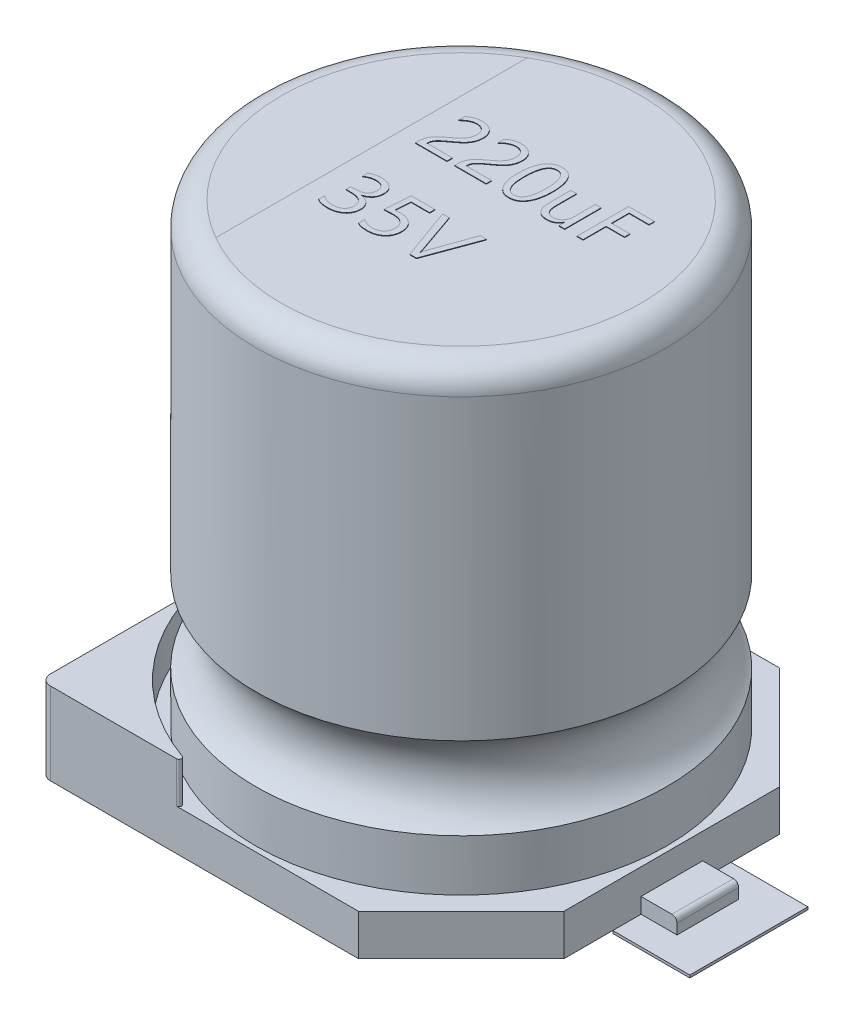
from build123d import *

# Parameters (mm, degrees)
SKETCH1_R             = 4
BOSS_EXTRUDE1_DEPTH   = 8.9
FILLET1_R             = 0.5
SKETCH3_W             = 8.2
SKETCH3_H             = 8.2
BOSS_EXTRUDE2_DEPTH   = 0.8
CHAMFER1_SIZE         = 2
BOSS_EXTRUDE3_DEPTH   = 0.8
FILLET2_R             = 0.05
SKETCH5_W             = 1.2
SKETCH5_H             = 0.3
BOSS_EXTRUDE4_DEPTH   = 0.7
FILLET3_R             = 0.1
FILLET4_R             = 0.2
BOSS_EXTRUDE5_DEPTH   = 0.01
SKETCH8_W             = 1.5
SKETCH8_H             = 2.3
BOSS_EXTRUDE6_DEPTH   = 0.05
BOSS_EXTRUDE6_2_DEPTH = 0.05


with BuildPart() as part:
    # Sketch1 → Boss-Extrude1 (new body)
    with BuildSketch(Plane(origin=(0, 0, 0), x_dir=(1, 0, 0), z_dir=(0, 1, 0))):
        with Locations(Location((0, 0, 0), (0, 0, 270))):
            Circle(SKETCH1_R)
    extrude(amount=BOSS_EXTRUDE1_DEPTH)

    # Sketch2 → Cut-Revolve1 (revolve, cut)
    with BuildSketch(Plane.XY, mode=Mode.PRIVATE) as cut_revolve1_sk:
        with BuildLine():
            Line((-4, 2.6), (-4, 1))
            ThreePointArc((-4, 1), (-3.6, 1.8), (-4, 2.6))
        make_face()
    revolve(cut_revolve1_sk.sketch.rotate(Axis((0, 0, 0), (0, 1, 0)), 270), axis=Axis((0, 0, 0), (0, 1, 0)), mode=Mode.SUBTRACT)

    # Fillet1
    fillet1_edges = [part.edges().sort_by_distance(p)[0] for p in [
        (0, 8.9, -4),
    ]]
    fillet(fillet1_edges, radius=FILLET1_R)

    # Sketch7 → Boss-Extrude5 (add)
    with BuildSketch(Plane(origin=(0, 8.9, 0), x_dir=(1, 0, 0), z_dir=(0, 1, 0))):
        with BuildLine():
            add(Edge.make_bspline(
                [(-0.930125802, 1.236413932), (-0.930259114, 1.243960657), (-0.93051816, 1.258625219), (-0.933217585, 1.279837795), (-0.937690446, 1.299566075), (-0.94413612, 1.317704314), (-0.951973463, 1.334404835), (-0.960965693, 1.349697986), (-0.971418987, 1.363460373), (-0.983054115, 1.375758821), (-0.996025952, 1.386549119), (-1.009932817, 1.396056003), (-1.025099003, 1.403860125), (-1.041211775, 1.410259329), (-1.058234602, 1.415152609), (-1.075995938, 1.418551202), (-1.094393633, 1.421022673), (-1.106926382, 1.42116749), (-1.113308368, 1.421241235)],
                knots=[0, 0, 0, 0, 1.229976224, 2.390051507, 3.479695195, 4.522256188, 5.522020781, 6.484042306, 7.409278233, 8.334041706, 9.238256106, 10.155631384, 11.07524972, 12.01315198, 12.978606878, 13.958184871, 14.960257312, 16, 16, 16, 16], degree=3))
            add(Edge.make_bspline(
                [(-1.113308368, 1.421241235), (-1.124306368, 1.420793323), (-1.146359305, 1.419895181), (-1.178872583, 1.413005858), (-1.210521013, 1.40241095), (-1.241171261, 1.388330314), (-1.270914684, 1.371112065), (-1.299540216, 1.351126167), (-1.326558952, 1.328232214), (-1.343084419, 1.311316023), (-1.351384026, 1.302820182)],
                knots=[0, 0, 0, 0, 0.965628522, 1.936256016, 2.907294264, 3.893428475, 4.89415936, 5.923092914, 6.956912204, 8, 8, 8, 8], degree=3))
            Line((-1.351384026, 1.302820182), (-1.351384026, 1.42083005))
            add(Edge.make_bspline(
                [(-1.351384026, 1.42083005), (-1.343296156, 1.428056334), (-1.327247541, 1.442395319), (-1.300949265, 1.460807107), (-1.273441566, 1.476863251), (-1.244116711, 1.490122212), (-1.212383716, 1.500911096), (-1.177569131, 1.507976142), (-1.139616176, 1.512689044), (-1.11325576, 1.513121421), (-1.099533697, 1.513346498)],
                knots=[0, 0, 0, 0, 0.944214214, 1.873587351, 2.791167331, 3.715694743, 4.672957526, 5.704638579, 6.805136737, 8, 8, 8, 8], degree=3))
            add(Edge.make_bspline(
                [(-1.099533697, 1.513346498), (-1.089518573, 1.513173106), (-1.069843055, 1.512832463), (-1.040894307, 1.509428442), (-1.013088783, 1.50395329), (-0.986554824, 1.496101614), (-0.961388457, 1.486300469), (-0.937913947, 1.474271219), (-0.915882319, 1.460578007), (-0.895977467, 1.444386562), (-0.877700025, 1.426484826), (-0.861591307, 1.406379899), (-0.847568662, 1.384232224), (-0.835639917, 1.360212472), (-0.826140454, 1.334227892), (-0.819073757, 1.306500097), (-0.815276422, 1.276814851), (-0.814682385, 1.256503336), (-0.814377447, 1.246076761)],
                knots=[0, 0, 0, 0, 1.090983638, 2.143325233, 3.171486627, 4.175802002, 5.154894058, 6.110112073, 7.046608623, 7.976171165, 8.900318033, 9.829880575, 10.776682924, 11.751922351, 12.746640181, 13.786318399, 14.863643788, 16, 16, 16, 16], degree=3))
            add(Edge.make_bspline(
                [(-0.814377447, 1.246076761), (-0.814531458, 1.236477477), (-0.814832315, 1.217725566), (-0.817296719, 1.190235014), (-0.821581293, 1.1641952), (-0.827589826, 1.139459526), (-0.835290949, 1.115847829), (-0.84452299, 1.092916153), (-0.85568986, 1.07066016), (-0.86861869, 1.04908191), (-0.883474866, 1.028235552), (-0.899578239, 1.007520928), (-0.918102774, 0.987695275), (-0.938046494, 0.967928986), (-0.95974411, 0.948246214), (-0.983540843, 0.928904371), (-1.008684502, 0.908805781), (-1.026491879, 0.895947355), (-1.035594552, 0.889374458)],
                knots=[0, 0, 0, 0, 1.04820289, 2.047632774, 3.011021103, 3.927694667, 4.824695696, 5.721103316, 6.624792092, 7.54122121, 8.465198091, 9.418974354, 10.404208392, 11.42559055, 12.48532564, 13.601687869, 14.7740444, 16, 16, 16, 16], degree=3))
            add(Edge.make_bspline(
                [(-1.035594552, 0.889374458), (-1.0467608, 0.881350886), (-1.068090672, 0.866024183), (-1.098747881, 0.844129319), (-1.125870649, 0.823476711), (-1.150532456, 0.804966697), (-1.172179314, 0.787392622), (-1.191598763, 0.770750028), (-1.208272601, 0.754276876), (-1.22317442, 0.738674783), (-1.235595167, 0.723065216), (-1.246188175, 0.70768586), (-1.254710812, 0.692205633), (-1.261205012, 0.676468123), (-1.265985539, 0.660195794), (-1.26919072, 0.642970859), (-1.271348594, 0.624626665), (-1.271523986, 0.611968811), (-1.271614289, 0.605451761)],
                knots=[0, 0, 0, 0, 1.708614713, 3.263812021, 4.68081799, 5.944582465, 7.094984069, 8.145209792, 9.120763434, 10.006432465, 10.824334392, 11.596681272, 12.324558074, 13.015639001, 13.708135059, 14.427947188, 15.190609529, 16, 16, 16, 16], degree=3))
            Line((-1.271614289, 0.605451761), (-0.776137315, 0.605451761))
            Line((-0.776137315, 0.605451761), (-0.776137315, 0.500188603))
            Line((-0.776137315, 0.500188603), (-1.390240934, 0.500188603))
            Line((-1.390240934, 0.500188603), (-1.390240934, 0.549530708))
            add(Edge.make_bspline(
                [(-1.390240934, 0.549530708), (-1.390112493, 0.559885514), (-1.389862806, 0.580015245), (-1.387089622, 0.609264891), (-1.382867614, 0.636617894), (-1.376895913, 0.662301406), (-1.368836385, 0.68672351), (-1.358190542, 0.710143676), (-1.345652347, 0.73310337), (-1.330653103, 0.755473675), (-1.31330216, 0.777442221), (-1.293576524, 0.799395571), (-1.271447887, 0.821266274), (-1.246596291, 0.843251792), (-1.219042309, 0.865837507), (-1.188798854, 0.889960508), (-1.15557999, 0.915331717), (-1.132316114, 0.932513516), (-1.1202985, 0.941389261)],
                knots=[0, 0, 0, 0, 0.993935718, 1.932209879, 2.81819806, 3.64973488, 4.461244427, 5.283013065, 6.11642225, 6.970511397, 7.865615548, 8.802227002, 9.802589001, 10.85121407, 11.986896714, 13.223140369, 14.565534561, 16, 16, 16, 16], degree=3))
            add(Edge.make_bspline(
                [(-1.1202985, 0.941389261), (-1.111641587, 0.947800515), (-1.094865557, 0.960224736), (-1.070876025, 0.978759101), (-1.049583208, 0.997425348), (-1.030060537, 1.015265375), (-1.012617763, 1.033103702), (-0.99707653, 1.050910344), (-0.983161212, 1.068610325), (-0.967478787, 1.091941675), (-0.951391267, 1.121372266), (-0.938714616, 1.1585384), (-0.931274338, 1.196908293), (-0.930513309, 1.223085047), (-0.930125802, 1.236413932)],
                knots=[0, 0, 0, 0, 1.05745301, 2.049213797, 2.974384311, 3.835963594, 4.644633175, 5.421714405, 6.155056683, 6.852828246, 8.179982614, 9.432988448, 10.692908862, 12, 12, 12, 12], degree=3))
        make_face()
        with BuildLine():
            add(Edge.make_bspline(
                [(-0.166967907, 1.236413932), (-0.167101219, 1.243960657), (-0.167360266, 1.258625219), (-0.17005969, 1.279837795), (-0.174532551, 1.299566075), (-0.180978225, 1.317704314), (-0.188815569, 1.334404835), (-0.197807799, 1.349697986), (-0.208261093, 1.363460373), (-0.21989622, 1.375758821), (-0.232868057, 1.386549119), (-0.246774922, 1.396056003), (-0.261941108, 1.403860125), (-0.27805388, 1.410259329), (-0.295076707, 1.415152609), (-0.312838044, 1.418551202), (-0.331235738, 1.421022673), (-0.343768488, 1.42116749), (-0.350150473, 1.421241235)],
                knots=[0, 0, 0, 0, 1.229976224, 2.390051507, 3.479695195, 4.522256188, 5.522020781, 6.484042306, 7.409278233, 8.334041706, 9.238256106, 10.155631384, 11.07524972, 12.01315198, 12.978606878, 13.958184871, 14.960257312, 16, 16, 16, 16], degree=3))
            add(Edge.make_bspline(
                [(-0.350150473, 1.421241235), (-0.361148474, 1.420793323), (-0.38320141, 1.419895181), (-0.415714688, 1.413005858), (-0.447363119, 1.40241095), (-0.478013367, 1.388330314), (-0.507756789, 1.371112065), (-0.536382322, 1.351126167), (-0.563401057, 1.328232214), (-0.579926524, 1.311316023), (-0.588226131, 1.302820182)],
                knots=[0, 0, 0, 0, 0.965628522, 1.936256016, 2.907294264, 3.893428475, 4.89415936, 5.923092914, 6.956912204, 8, 8, 8, 8], degree=3))
            Line((-0.588226131, 1.302820182), (-0.588226131, 1.42083005))
            add(Edge.make_bspline(
                [(-0.588226131, 1.42083005), (-0.580138261, 1.428056334), (-0.564089646, 1.442395319), (-0.53779137, 1.460807107), (-0.510283672, 1.476863251), (-0.480958816, 1.490122212), (-0.449225821, 1.500911096), (-0.414411236, 1.507976142), (-0.376458281, 1.512689044), (-0.350097865, 1.513121421), (-0.336375802, 1.513346498)],
                knots=[0, 0, 0, 0, 0.944214214, 1.873587351, 2.791167331, 3.715694743, 4.672957526, 5.704638579, 6.805136737, 8, 8, 8, 8], degree=3))
            add(Edge.make_bspline(
                [(-0.336375802, 1.513346498), (-0.326360678, 1.513173106), (-0.30668516, 1.512832463), (-0.277736412, 1.509428442), (-0.249930889, 1.50395329), (-0.223396929, 1.496101614), (-0.198230563, 1.486300469), (-0.174756053, 1.474271219), (-0.152724424, 1.460578007), (-0.132819572, 1.444386562), (-0.11454213, 1.426484826), (-0.098433412, 1.406379899), (-0.084410767, 1.384232224), (-0.072482022, 1.360212472), (-0.062982559, 1.334227892), (-0.055915862, 1.306500097), (-0.052118527, 1.276814851), (-0.051524491, 1.256503336), (-0.051219552, 1.246076761)],
                knots=[0, 0, 0, 0, 1.090983638, 2.143325233, 3.171486627, 4.175802002, 5.154894058, 6.110112073, 7.046608623, 7.976171165, 8.900318033, 9.829880575, 10.776682924, 11.751922351, 12.746640181, 13.786318399, 14.863643788, 16, 16, 16, 16], degree=3))
            add(Edge.make_bspline(
                [(-0.051219552, 1.246076761), (-0.051373564, 1.236477477), (-0.05167442, 1.217725566), (-0.054138825, 1.190235014), (-0.058423399, 1.1641952), (-0.064431931, 1.139459526), (-0.072133054, 1.115847829), (-0.081365096, 1.092916153), (-0.092531965, 1.07066016), (-0.105460795, 1.04908191), (-0.120316971, 1.028235552), (-0.136420344, 1.007520928), (-0.154944879, 0.987695275), (-0.1748886, 0.967928986), (-0.196586215, 0.948246214), (-0.220382949, 0.928904371), (-0.245526608, 0.908805781), (-0.263333984, 0.895947355), (-0.272436657, 0.889374458)],
                knots=[0, 0, 0, 0, 1.04820289, 2.047632774, 3.011021103, 3.927694667, 4.824695696, 5.721103316, 6.624792092, 7.54122121, 8.465198091, 9.418974354, 10.404208392, 11.42559055, 12.48532564, 13.601687869, 14.7740444, 16, 16, 16, 16], degree=3))
            add(Edge.make_bspline(
                [(-0.272436657, 0.889374458), (-0.283602905, 0.881350886), (-0.304932777, 0.866024183), (-0.335589986, 0.844129319), (-0.362712754, 0.823476711), (-0.387374561, 0.804966697), (-0.409021419, 0.787392622), (-0.428440868, 0.770750028), (-0.445114706, 0.754276876), (-0.460016525, 0.738674783), (-0.472437273, 0.723065216), (-0.48303028, 0.70768586), (-0.491552917, 0.692205633), (-0.498047118, 0.676468123), (-0.502827644, 0.660195794), (-0.506032825, 0.642970859), (-0.508190699, 0.624626665), (-0.508366091, 0.611968811), (-0.508456394, 0.605451761)],
                knots=[0, 0, 0, 0, 1.708614713, 3.263812021, 4.68081799, 5.944582465, 7.094984069, 8.145209792, 9.120763434, 10.006432465, 10.824334392, 11.596681272, 12.324558074, 13.015639001, 13.708135059, 14.427947188, 15.190609529, 16, 16, 16, 16], degree=3))
            Line((-0.508456394, 0.605451761), (-0.012979421, 0.605451761))
            Line((-0.012979421, 0.605451761), (-0.012979421, 0.500188603))
            Line((-0.012979421, 0.500188603), (-0.627083039, 0.500188603))
            Line((-0.627083039, 0.500188603), (-0.627083039, 0.549530708))
            add(Edge.make_bspline(
                [(-0.627083039, 0.549530708), (-0.626954599, 0.559885514), (-0.626704911, 0.580015245), (-0.623931727, 0.609264891), (-0.619709719, 0.636617894), (-0.613738018, 0.662301406), (-0.60567849, 0.68672351), (-0.595032648, 0.710143676), (-0.582494452, 0.73310337), (-0.567495209, 0.755473675), (-0.550144265, 0.777442221), (-0.530418629, 0.799395571), (-0.508289992, 0.821266274), (-0.483438396, 0.843251792), (-0.455884415, 0.865837507), (-0.425640959, 0.889960508), (-0.392422095, 0.915331717), (-0.369158219, 0.932513516), (-0.357140605, 0.941389261)],
                knots=[0, 0, 0, 0, 0.993935718, 1.932209879, 2.81819806, 3.64973488, 4.461244427, 5.283013065, 6.11642225, 6.970511397, 7.865615548, 8.802227002, 9.802589001, 10.85121407, 11.986896714, 13.223140369, 14.565534561, 16, 16, 16, 16], degree=3))
            add(Edge.make_bspline(
                [(-0.357140605, 0.941389261), (-0.348483693, 0.947800515), (-0.331707662, 0.960224736), (-0.30771813, 0.978759101), (-0.286425314, 0.997425348), (-0.266902643, 1.015265375), (-0.249459869, 1.033103702), (-0.233918636, 1.050910344), (-0.220003318, 1.068610325), (-0.204320892, 1.091941675), (-0.188233373, 1.121372266), (-0.175556721, 1.1585384), (-0.168116443, 1.196908293), (-0.167355414, 1.223085047), (-0.166967907, 1.236413932)],
                knots=[0, 0, 0, 0, 1.05745301, 2.049213797, 2.974384311, 3.835963594, 4.644633175, 5.421714405, 6.155056683, 6.852828246, 8.179982614, 9.432988448, 10.692908862, 12, 12, 12, 12], degree=3))
        make_face()
        with BuildLine():
            add(Edge.make_bspline(
                [(0.768270579, 1.004711629), (0.767984026, 0.984557566), (0.767426863, 0.945370772), (0.763418175, 0.888304877), (0.756186625, 0.834774088), (0.746455105, 0.78474756), (0.733960132, 0.738431643), (0.718972384, 0.695758481), (0.701389132, 0.65682236), (0.681174329, 0.621736309), (0.658846167, 0.590281443), (0.633450707, 0.563262978), (0.606078237, 0.539685765), (0.575992083, 0.520517467), (0.54373231, 0.505217818), (0.50901846, 0.495007822), (0.472430214, 0.488007663), (0.447238608, 0.487360705), (0.434389, 0.487030708)],
                knots=[0, 0, 0, 0, 1.398980466, 2.720124312, 3.96812368, 5.146432578, 6.255415985, 7.295087503, 8.282879546, 9.216336252, 10.102253837, 10.953825877, 11.784043498, 12.603506409, 13.42284504, 14.253498671, 15.109153359, 16, 16, 16, 16], degree=3))
            add(Edge.make_bspline(
                [(0.434389, 0.487030708), (0.422230969, 0.487403858), (0.398436735, 0.488134142), (0.363754287, 0.494513325), (0.331026039, 0.504747043), (0.300408199, 0.519260787), (0.271987746, 0.537718507), (0.246029721, 0.560078852), (0.222359986, 0.586154425), (0.200953607, 0.615858168), (0.182100935, 0.649361911), (0.165598018, 0.686395783), (0.151799052, 0.727057537), (0.140003843, 0.771117384), (0.131133053, 0.818768253), (0.124605791, 0.869693802), (0.120647388, 0.923988105), (0.120245611, 0.961256343), (0.120038671, 0.980451761)],
                knots=[0, 0, 0, 0, 0.888155269, 1.738190458, 2.568434008, 3.38864091, 4.207101744, 5.03849325, 5.886044594, 6.7759361, 7.709272942, 8.69152049, 9.735599895, 10.845083744, 12.023162705, 13.27590253, 14.596923554, 16, 16, 16, 16], degree=3))
            add(Edge.make_bspline(
                [(0.120038671, 0.980451761), (0.120314337, 1.001497645), (0.120850059, 1.042397677), (0.124995631, 1.101825233), (0.131680111, 1.157428823), (0.141006661, 1.20925434), (0.153313788, 1.257126333), (0.168031411, 1.301093022), (0.18526661, 1.341086758), (0.205206931, 1.376997022), (0.227640682, 1.40900922), (0.252881939, 1.436746934), (0.280558491, 1.460461121), (0.31096194, 1.479788402), (0.343763603, 1.49483533), (0.37896513, 1.505504416), (0.416305751, 1.512337738), (0.442033999, 1.513005818), (0.455153803, 1.513346498)],
                knots=[0, 0, 0, 0, 1.426258677, 2.771754592, 4.035124818, 5.220331935, 6.337825632, 7.382114204, 8.359741748, 9.284994213, 10.161296122, 11.002979272, 11.820109764, 12.624106341, 13.436709906, 14.257961594, 15.111668944, 16, 16, 16, 16], degree=3))
            add(Edge.make_bspline(
                [(0.455153803, 1.513346498), (0.467789027, 1.512959369), (0.492452111, 1.512203721), (0.528206054, 1.506094994), (0.561617433, 1.496387059), (0.592397229, 1.482139609), (0.620789145, 1.464156343), (0.646779028, 1.442121729), (0.669979565, 1.415950319), (0.691035204, 1.3860259), (0.709055435, 1.351883719), (0.725299825, 1.31408476), (0.738401979, 1.272056949), (0.749543511, 1.226276634), (0.757771097, 1.176431001), (0.763905061, 1.12277945), (0.767619878, 1.065070853), (0.768048881, 1.025276442), (0.768270579, 1.004711629)],
                knots=[0, 0, 0, 0, 0.899241396, 1.755257189, 2.575108327, 3.369931066, 4.161902333, 4.96169813, 5.78762661, 6.645962214, 7.56082504, 8.531597655, 9.571777694, 10.691464586, 11.88443752, 13.166498411, 14.535713275, 16, 16, 16, 16], degree=3))
        make_face()
        with BuildLine():
            add(Edge.make_bspline(
                [(0.651699856, 0.993198471), (0.651522889, 1.010469562), (0.651180034, 1.043930687), (0.649093063, 1.092507874), (0.644804237, 1.137667761), (0.639767405, 1.179587018), (0.632455014, 1.218050581), (0.624029426, 1.253280964), (0.613704359, 1.285169971), (0.601960849, 1.313719893), (0.588489921, 1.338955551), (0.573519063, 1.360931968), (0.556847658, 1.379614653), (0.538509059, 1.394887973), (0.518583963, 1.406866101), (0.496880754, 1.414960968), (0.473790601, 1.420441518), (0.457791004, 1.42097051), (0.449602816, 1.421241235)],
                knots=[0, 0, 0, 0, 1.581181307, 3.063391078, 4.449305256, 5.73327765, 6.92683892, 8.031533681, 9.047337031, 9.992258722, 10.853979057, 11.661441156, 12.421081853, 13.138403699, 13.838846326, 14.537910874, 15.251739941, 16, 16, 16, 16], degree=3))
            add(Edge.make_bspline(
                [(0.449602816, 1.421241235), (0.441008756, 1.420956637), (0.424138756, 1.420397978), (0.39975072, 1.415083426), (0.376953282, 1.406638965), (0.35592608, 1.394518687), (0.336701034, 1.378867186), (0.319054913, 1.359920592), (0.303263696, 1.337502337), (0.289112272, 1.311820005), (0.276458182, 1.28281579), (0.26607136, 1.250213365), (0.256697728, 1.214429829), (0.249535481, 1.175157744), (0.243480639, 1.132653105), (0.239548982, 1.086666414), (0.23703384, 1.037292279), (0.236754015, 1.003207366), (0.236609395, 0.985591563)],
                knots=[0, 0, 0, 0, 0.764995805, 1.501674303, 2.212925961, 2.924256282, 3.65393935, 4.414460527, 5.224546987, 6.091227052, 7.023912083, 8.039810551, 9.137474513, 10.318540051, 11.595133009, 12.962565651, 14.430189818, 16, 16, 16, 16], degree=3))
            add(Edge.make_bspline(
                [(0.236609395, 0.985591563), (0.236755854, 0.969209241), (0.237039756, 0.937452912), (0.239543531, 0.891364271), (0.243523341, 0.848405362), (0.249348493, 0.808633363), (0.256283216, 0.771954437), (0.265416837, 0.738621381), (0.275777484, 0.708264032), (0.288118237, 0.681192385), (0.301765507, 0.656982181), (0.317577808, 0.636351776), (0.334643822, 0.618478865), (0.35379437, 0.604260881), (0.374382427, 0.592951387), (0.396618963, 0.58487104), (0.420546736, 0.580072872), (0.437039497, 0.579453407), (0.445490974, 0.579135971)],
                knots=[0, 0, 0, 0, 1.543513286, 2.992024866, 4.347767877, 5.607075833, 6.778486024, 7.862468221, 8.861099137, 9.797386861, 10.662401359, 11.473455982, 12.240599663, 12.983190345, 13.711379138, 14.446775782, 15.204072658, 16, 16, 16, 16], degree=3))
            add(Edge.make_bspline(
                [(0.445490974, 0.579135971), (0.453803181, 0.579462603), (0.470087117, 0.580102486), (0.493797116, 0.584815964), (0.515775862, 0.593201099), (0.536230147, 0.604593384), (0.554849281, 0.619420262), (0.571839842, 0.637397511), (0.587421335, 0.658496883), (0.600698358, 0.683184252), (0.61303245, 0.710733256), (0.623309355, 0.741627939), (0.632165265, 0.77569519), (0.639188306, 0.813015594), (0.645031646, 0.85347046), (0.648698582, 0.897202574), (0.651291767, 0.944099177), (0.651560842, 0.976472965), (0.651699856, 0.993198471)],
                knots=[0, 0, 0, 0, 0.775360401, 1.518961016, 2.243373551, 2.96192122, 3.694889719, 4.454670758, 5.264184671, 6.134259122, 7.064577354, 8.077594077, 9.167837551, 10.346585987, 11.618858978, 12.979815247, 14.439659868, 16, 16, 16, 16], degree=3))
        make_face(mode=Mode.SUBTRACT)
        with BuildLine():
            Line((1.513336369, 0.500188603), (1.399438343, 0.500188603))
            Line((1.399438343, 0.500188603), (1.399438343, 0.612441892))
            Line((1.399438343, 0.612441892), (1.396765645, 0.612441892))
            add(Edge.make_bspline(
                [(1.396765645, 0.612441892), (1.390720663, 0.602460299), (1.378922171, 0.5829784), (1.357224617, 0.557406109), (1.333497285, 0.535340747), (1.30679844, 0.517874984), (1.27796377, 0.503876254), (1.246605155, 0.493991312), (1.212766798, 0.488233325), (1.189414343, 0.487439271), (1.177398869, 0.487030708)],
                knots=[0, 0, 0, 0, 1.050691007, 2.050720406, 3.012962404, 3.962401766, 4.915874185, 5.894932476, 6.916885468, 8, 8, 8, 8], degree=3))
            add(Edge.make_bspline(
                [(1.177398869, 0.487030708), (1.167106673, 0.487257871), (1.147213655, 0.487696936), (1.11834269, 0.491353296), (1.091359331, 0.496789144), (1.066537263, 0.505487129), (1.043447569, 0.515877394), (1.022427463, 0.528850187), (1.003437756, 0.544280218), (0.986572548, 0.56212546), (0.971356904, 0.582119485), (0.958722421, 0.604808693), (0.947754222, 0.629646774), (0.938794621, 0.656780083), (0.931760999, 0.68627913), (0.926955997, 0.718120739), (0.92409119, 0.75232886), (0.923696159, 0.775881872), (0.923492619, 0.78801755)],
                knots=[0, 0, 0, 0, 1.09540131, 2.117219514, 3.094696566, 4.020015321, 4.911365501, 5.786165053, 6.642013186, 7.509079247, 8.394916856, 9.30993597, 10.267157936, 11.282441873, 12.347880503, 13.49236844, 14.707944063, 16, 16, 16, 16], degree=3))
            Line((0.923492619, 0.78801755), (0.923492619, 1.210714919))
            Line((0.923492619, 1.210714919), (1.036568277, 1.210714919))
            Line((1.036568277, 1.210714919), (1.036568277, 0.804053735))
            add(Edge.make_bspline(
                [(1.036568277, 0.804053735), (1.036658129, 0.79500285), (1.03683264, 0.777424219), (1.038994686, 0.751898193), (1.042143232, 0.72804247), (1.046826816, 0.705955212), (1.053044542, 0.68569587), (1.060388214, 0.66715835), (1.068975395, 0.650310847), (1.079241694, 0.635355566), (1.090611126, 0.621958112), (1.103608072, 0.610479502), (1.117877537, 0.600820717), (1.133413594, 0.592673278), (1.150370126, 0.586537416), (1.168663857, 0.582288295), (1.188210634, 0.579518344), (1.201717402, 0.57926565), (1.208648869, 0.579135971)],
                knots=[0, 0, 0, 0, 1.343703186, 2.609740898, 3.801442941, 4.915248641, 5.95827345, 6.944754588, 7.873313373, 8.759642607, 9.632786239, 10.476245362, 11.325882859, 12.18618061, 13.074785555, 13.995503533, 14.971323121, 16, 16, 16, 16], degree=3))
            add(Edge.make_bspline(
                [(1.208648869, 0.579135971), (1.215444264, 0.579340895), (1.228822529, 0.579744332), (1.248382544, 0.582703586), (1.267049545, 0.587339775), (1.284654366, 0.594262065), (1.301392063, 0.602948489), (1.317350699, 0.613434023), (1.332147143, 0.626102121), (1.345940795, 0.640486012), (1.358314303, 0.656498858), (1.369603949, 0.673539607), (1.378805849, 0.692024015), (1.38648315, 0.711539654), (1.39212846, 0.732324927), (1.396555207, 0.754141181), (1.398974255, 0.77727204), (1.39928124, 0.793083669), (1.399438343, 0.801175445)],
                knots=[0, 0, 0, 0, 0.99348202, 1.955893163, 2.886897847, 3.800751478, 4.715209456, 5.640858053, 6.586634716, 7.557773505, 8.550193329, 9.542613152, 10.542143211, 11.563936364, 12.604722674, 13.687744657, 14.816677783, 16, 16, 16, 16], degree=3))
            Line((1.399438343, 0.801175445), (1.399438343, 1.210714919))
            Line((1.399438343, 1.210714919), (1.513336369, 1.210714919))
            Line((1.513336369, 1.210714919), (1.513336369, 0.500188603))
        make_face()
        Polygon((2.261897224, 1.394925445), (1.873328145, 1.394925445), (1.873328145, 1.052820182), (2.232703145, 1.052820182), (2.232703145, 0.947557024), (1.873328145, 0.947557024), (1.873328145, 0.500188603), (1.756757421, 0.500188603), (1.756757421, 1.500188603), (2.261897224, 1.500188603), align=None)
        with BuildLine():
            add(Edge.make_bspline(
                [(-0.804714618, -1.148129406), (-0.805031256, -1.159112704), (-0.8056537, -1.180703538), (-0.810545623, -1.212322365), (-0.81821854, -1.242521604), (-0.829485239, -1.270996221), (-0.843387288, -1.297682296), (-0.860079885, -1.322502116), (-0.879355425, -1.34528654), (-0.901348015, -1.36596671), (-0.925648549, -1.384414873), (-0.952206937, -1.40091553), (-0.981289155, -1.41466786), (-1.012355786, -1.426716232), (-1.04546405, -1.436091712), (-1.080316635, -1.442913456), (-1.116853492, -1.446775249), (-1.141739816, -1.447372584), (-1.154426789, -1.447677104)],
                knots=[0, 0, 0, 0, 1.019101285, 2.003336971, 2.96304981, 3.905745115, 4.839035233, 5.7512084, 6.676507669, 7.603532857, 8.547600853, 9.50446321, 10.500287074, 11.529287479, 12.594462435, 13.68984929, 14.822292144, 16, 16, 16, 16], degree=3))
            add(Edge.make_bspline(
                [(-1.154426789, -1.447677104), (-1.165944596, -1.447526788), (-1.188459435, -1.447232953), (-1.221336029, -1.444725511), (-1.25237966, -1.440705925), (-1.281633165, -1.434909093), (-1.309040274, -1.4275651), (-1.334761093, -1.418788037), (-1.35857901, -1.408099658), (-1.373314855, -1.399493208), (-1.380578105, -1.395251117)],
                knots=[0, 0, 0, 0, 1.175724286, 2.298288404, 3.363967618, 4.369719485, 5.340477689, 6.258710396, 7.141724009, 8, 8, 8, 8], degree=3))
            Line((-1.380578105, -1.395251117), (-1.380578105, -1.276624472))
            add(Edge.make_bspline(
                [(-1.380578105, -1.276624472), (-1.372113234, -1.282940122), (-1.355363809, -1.295436887), (-1.328682314, -1.311438333), (-1.301220419, -1.325144501), (-1.272730503, -1.336277689), (-1.24334211, -1.344879631), (-1.213092942, -1.351082153), (-1.181936645, -1.35488503), (-1.160810908, -1.355340909), (-1.150109355, -1.35557184)],
                knots=[0, 0, 0, 0, 1.020300071, 2.018866019, 3.00237846, 3.983992981, 4.971245873, 5.95856543, 6.965881301, 8, 8, 8, 8], degree=3))
            add(Edge.make_bspline(
                [(-1.150109355, -1.35557184), (-1.141675575, -1.355410944), (-1.12511342, -1.355094978), (-1.100885827, -1.352709018), (-1.07798391, -1.348242785), (-1.056277923, -1.342703383), (-1.036079887, -1.334907669), (-1.017141665, -1.326003007), (-0.999750075, -1.315404178), (-0.983836357, -1.303503071), (-0.969564045, -1.290051617), (-0.95698736, -1.275241922), (-0.94619398, -1.259007402), (-0.937164125, -1.241502035), (-0.929860842, -1.222799256), (-0.925060693, -1.202799784), (-0.921829579, -1.181814566), (-0.921469052, -1.167399238), (-0.921285342, -1.160053748)],
                knots=[0, 0, 0, 0, 1.193357867, 2.343501928, 3.438959172, 4.492721389, 5.508499269, 6.497400075, 7.450321688, 8.385111628, 9.304331213, 10.219398486, 11.128434492, 12.056561698, 13.002003861, 13.96156304, 14.961291981, 16, 16, 16, 16], degree=3))
            add(Edge.make_bspline(
                [(-0.921285342, -1.160053748), (-0.921452323, -1.152022907), (-0.921777803, -1.136369207), (-0.925179058, -1.1137093), (-0.930453269, -1.092500743), (-0.938055121, -1.072844694), (-0.948003418, -1.05483614), (-0.960076511, -1.038435383), (-0.974193271, -1.02348093), (-0.990538325, -1.010044392), (-1.009173514, -0.998365958), (-1.029907565, -0.988216965), (-1.052840822, -0.979913093), (-1.077856579, -0.972919607), (-1.105056449, -0.967378448), (-1.134461499, -0.963559604), (-1.165973689, -0.961326297), (-1.187660477, -0.961002062), (-1.198834684, -0.960834998)],
                knots=[0, 0, 0, 0, 0.990580855, 1.930838357, 2.821223158, 3.683604226, 4.524093985, 5.353097825, 6.190816286, 7.056179088, 7.957307443, 8.899275577, 9.900203706, 10.963355231, 12.103032959, 13.323269139, 14.620803362, 16, 16, 16, 16], degree=3))
            Line((-1.198834684, -0.960834998), (-1.281277118, -0.960834998))
            Line((-1.281277118, -0.960834998), (-1.281277118, -0.868729735))
            Line((-1.281277118, -0.868729735), (-1.202946526, -0.868729735))
            add(Edge.make_bspline(
                [(-1.202946526, -0.868729735), (-1.193007467, -0.868540155), (-1.173792977, -0.868173654), (-1.145891773, -0.866262661), (-1.119977347, -0.862427464), (-1.0958372, -0.857749578), (-1.073772669, -0.85100883), (-1.053424255, -0.843334983), (-1.035072614, -0.83388113), (-1.018743146, -0.8228767), (-1.004084717, -0.810708342), (-0.991571883, -0.796887751), (-0.980872113, -0.781651578), (-0.972281366, -0.764877929), (-0.965408434, -0.74669158), (-0.960818977, -0.727053228), (-0.957834636, -0.706060275), (-0.957458433, -0.691588816), (-0.95726396, -0.684108025)],
                knots=[0, 0, 0, 0, 1.361615543, 2.632316345, 3.827071242, 4.948204408, 5.996555552, 6.983205608, 7.923628678, 8.816616634, 9.675964955, 10.526501328, 11.362408219, 12.21888074, 13.10109775, 14.018614351, 14.97575406, 16, 16, 16, 16], degree=3))
            add(Edge.make_bspline(
                [(-0.95726396, -0.684108025), (-0.95745195, -0.677182738), (-0.95781575, -0.663780842), (-0.959752018, -0.644352256), (-0.963511473, -0.626333625), (-0.9686285, -0.609586717), (-0.975175194, -0.594110872), (-0.983215575, -0.580000661), (-0.992865472, -0.56726574), (-1.003850801, -0.555807254), (-1.016457943, -0.545758273), (-1.030517917, -0.537167528), (-1.045933022, -0.529751133), (-1.062837544, -0.523789767), (-1.081125224, -0.519049017), (-1.101022061, -0.515876849), (-1.122307578, -0.513739142), (-1.137014352, -0.513558989), (-1.144558368, -0.513466577)],
                knots=[0, 0, 0, 0, 1.144475627, 2.214802505, 3.220728203, 4.180545248, 5.103803117, 5.991379618, 6.856426605, 7.737261095, 8.607258638, 9.512214307, 10.4541674, 11.428302948, 12.469117141, 13.571076801, 14.754054657, 16, 16, 16, 16], degree=3))
            add(Edge.make_bspline(
                [(-1.144558368, -0.513466577), (-1.153271214, -0.513660574), (-1.170614533, -0.514046732), (-1.196460904, -0.517276541), (-1.221912992, -0.522346096), (-1.246927429, -0.529619694), (-1.271475426, -0.538890374), (-1.295607949, -0.550337615), (-1.319498714, -0.563554497), (-1.334674891, -0.573987828), (-1.342337973, -0.579256051)],
                knots=[0, 0, 0, 0, 0.986643374, 1.963958899, 2.945918741, 3.923727424, 4.911347552, 5.914946884, 6.94716999, 8, 8, 8, 8], degree=3))
            Line((-1.342337973, -0.579256051), (-1.342337973, -0.475020854))
            add(Edge.make_bspline(
                [(-1.342337973, -0.475020854), (-1.334313811, -0.470712742), (-1.318143628, -0.462031095), (-1.292571059, -0.451268954), (-1.265941961, -0.441958124), (-1.238204929, -0.434317891), (-1.209243276, -0.428689844), (-1.179280012, -0.424273374), (-1.148094441, -0.421830319), (-1.126949941, -0.421519521), (-1.116186657, -0.421361314)],
                knots=[0, 0, 0, 0, 0.92965156, 1.873421247, 2.829591002, 3.809240957, 4.808444756, 5.840751768, 6.9008678, 8, 8, 8, 8], degree=3))
            add(Edge.make_bspline(
                [(-1.116186657, -0.421361314), (-1.10603432, -0.421533555), (-1.086085178, -0.421872005), (-1.057011528, -0.425261363), (-1.029331999, -0.430533872), (-1.003303978, -0.438196717), (-0.97876251, -0.447568336), (-0.956081226, -0.458933787), (-0.935194447, -0.471902725), (-0.916167806, -0.486560316), (-0.899075553, -0.502817061), (-0.883904639, -0.52061409), (-0.87088699, -0.540078482), (-0.860026398, -0.561049279), (-0.851296722, -0.583352405), (-0.845195716, -0.606886134), (-0.841359328, -0.631556179), (-0.840918137, -0.648389153), (-0.840693236, -0.656969867)],
                knots=[0, 0, 0, 0, 1.197034325, 2.352148888, 3.447599133, 4.516879017, 5.548177483, 6.54231138, 7.50454852, 8.443935387, 9.370188229, 10.282043863, 11.19676135, 12.125937188, 13.062642227, 14.015530744, 14.988404392, 16, 16, 16, 16], degree=3))
            add(Edge.make_bspline(
                [(-0.840693236, -0.656969867), (-0.840866106, -0.664923951), (-0.841205106, -0.680522009), (-0.843418775, -0.70335583), (-0.847388687, -0.72505397), (-0.852678003, -0.745714975), (-0.859618195, -0.765301715), (-0.868439713, -0.783701759), (-0.87833428, -0.801172273), (-0.890109896, -0.817388144), (-0.903180705, -0.832662693), (-0.918140027, -0.846604611), (-0.934445761, -0.859678035), (-0.952398977, -0.871524776), (-0.971771396, -0.882526463), (-0.992784165, -0.892120699), (-1.01536155, -0.900565727), (-1.031043549, -0.905341763), (-1.039089618, -0.907792235)],
                knots=[0, 0, 0, 0, 1.096960776, 2.151153854, 3.159618439, 4.136134396, 5.089743263, 6.019833047, 6.947085499, 7.854572729, 8.77922067, 9.715197914, 10.670163965, 11.658363707, 12.678233686, 13.739646337, 14.840265149, 16, 16, 16, 16], degree=3))
            Line((-1.039089618, -0.907792235), (-1.039089618, -0.910670525))
            add(Edge.make_bspline(
                [(-1.039089618, -0.910670525), (-1.030783191, -0.911806902), (-1.014419407, -0.914045583), (-0.990398194, -0.919043225), (-0.967569, -0.926484516), (-0.945531067, -0.934924636), (-0.924858448, -0.945294604), (-0.905323232, -0.956753399), (-0.887435698, -0.969938123), (-0.871089828, -0.984644676), (-0.856302948, -1.000686878), (-0.842983429, -1.017995709), (-0.831734606, -1.036845889), (-0.822010133, -1.056826634), (-0.814139848, -1.077997543), (-0.808600806, -1.100404754), (-0.805236443, -1.123903377), (-0.804890523, -1.139962925), (-0.804714618, -1.148129406)],
                knots=[0, 0, 0, 0, 1.09354583, 2.154301538, 3.194710689, 4.222252129, 5.229688408, 6.207785533, 7.17326046, 8.12275326, 9.071656757, 10.015663309, 10.966165492, 11.929693435, 12.91109378, 13.906239898, 14.935296686, 16, 16, 16, 16], degree=3))
        make_face()
        with BuildLine():
            add(Edge.make_bspline(
                [(-0.03045475, -1.127775788), (-0.030802403, -1.139574748), (-0.031484148, -1.162712395), (-0.035906733, -1.196669956), (-0.04406565, -1.228776685), (-0.054874076, -1.259148157), (-0.068806492, -1.287475253), (-0.085215565, -1.313832799), (-0.104354349, -1.338196132), (-0.126176369, -1.360347166), (-0.150424426, -1.380386349), (-0.177374985, -1.397725884), (-0.206473587, -1.413005561), (-0.238108655, -1.425393112), (-0.271594661, -1.435646199), (-0.307107851, -1.44238049), (-0.344344432, -1.4469306), (-0.36980431, -1.447424321), (-0.382839618, -1.447677104)],
                knots=[0, 0, 0, 0, 1.056864167, 2.072500419, 3.059485391, 4.018613275, 4.954681828, 5.881162702, 6.794724112, 7.723560484, 8.661137091, 9.605998599, 10.588833302, 11.59982216, 12.644532083, 13.720683555, 14.833003331, 16, 16, 16, 16], degree=3))
            add(Edge.make_bspline(
                [(-0.382839618, -1.447677104), (-0.394011781, -1.44755688), (-0.415687047, -1.447323631), (-0.44705982, -1.445589255), (-0.476188121, -1.442162006), (-0.503154717, -1.438066715), (-0.52787873, -1.432285861), (-0.550359407, -1.425324282), (-0.570695721, -1.417259251), (-0.582942468, -1.410454138), (-0.588842907, -1.407175459)],
                knots=[0, 0, 0, 0, 1.263126396, 2.450608766, 3.550077914, 4.578015321, 5.532741343, 6.41739748, 7.237507678, 8, 8, 8, 8], degree=3))
            Line((-0.588842907, -1.407175459), (-0.588842907, -1.289782367))
            add(Edge.make_bspline(
                [(-0.588842907, -1.289782367), (-0.580486624, -1.295047632), (-0.563958074, -1.305462213), (-0.538240806, -1.318689721), (-0.512514242, -1.330073303), (-0.486640452, -1.339444348), (-0.46057513, -1.346605094), (-0.434330806, -1.351776104), (-0.407933099, -1.354979568), (-0.39024973, -1.355374304), (-0.381400473, -1.35557184)],
                knots=[0, 0, 0, 0, 1.073575538, 2.123509434, 3.141212585, 4.131255582, 5.1129617, 6.077547705, 7.037950563, 8, 8, 8, 8], degree=3))
            add(Edge.make_bspline(
                [(-0.381400473, -1.35557184), (-0.372617836, -1.355388981), (-0.355407639, -1.355030654), (-0.330324015, -1.351802344), (-0.306442828, -1.347029456), (-0.284039183, -1.339744061), (-0.263136581, -1.330749682), (-0.243776786, -1.320167604), (-0.22602342, -1.308039635), (-0.209871884, -1.29419492), (-0.19549013, -1.278678747), (-0.182606955, -1.261858724), (-0.171937685, -1.243311522), (-0.162893185, -1.223573267), (-0.155556814, -1.20255171), (-0.150878043, -1.180358364), (-0.147550102, -1.157275006), (-0.147202924, -1.141563111), (-0.147025473, -1.133532367)],
                knots=[0, 0, 0, 0, 1.158660806, 2.270477318, 3.333079092, 4.368579658, 5.373363954, 6.332745853, 7.27608927, 8.206156569, 9.134110276, 10.063957633, 10.99630925, 11.951503368, 12.926911662, 13.927616427, 14.940752784, 16, 16, 16, 16], degree=3))
            add(Edge.make_bspline(
                [(-0.147025473, -1.133532367), (-0.147214801, -1.125504516), (-0.147585215, -1.109798279), (-0.150720263, -1.086857782), (-0.15588238, -1.065263813), (-0.162741731, -1.044864207), (-0.172226903, -1.026114831), (-0.183233505, -1.008384945), (-0.196845966, -0.992409341), (-0.212000946, -0.977427808), (-0.229393724, -0.964366436), (-0.248489767, -0.952710772), (-0.269472669, -0.942803068), (-0.292445879, -0.9351487), (-0.317112227, -0.928920598), (-0.343575951, -0.924473626), (-0.371954044, -0.921743454), (-0.391468002, -0.921491479), (-0.4015485, -0.921361314)],
                knots=[0, 0, 0, 0, 1.024220939, 2.003855773, 2.947861307, 3.855091956, 4.742976808, 5.623725423, 6.511739495, 7.414744547, 8.338353125, 9.280330718, 10.266270024, 11.292393647, 12.365736532, 13.510265708, 14.713855882, 16, 16, 16, 16], degree=3))
            add(Edge.make_bspline(
                [(-0.4015485, -0.921361314), (-0.408402298, -0.921394443), (-0.422523667, -0.921462702), (-0.444035494, -0.922254008), (-0.466114501, -0.922665261), (-0.488237145, -0.923887785), (-0.510116155, -0.924724478), (-0.531286091, -0.926244892), (-0.551239012, -0.92779629), (-0.564037249, -0.929147098), (-0.570134026, -0.92979059)],
                knots=[0, 0, 0, 0, 0.974070636, 2.006947305, 3.059296761, 4.112367188, 5.155707916, 6.170982707, 7.128699404, 8, 8, 8, 8], degree=3))
            Line((-0.570134026, -0.92979059), (-0.536211329, -0.434519209))
            Line((-0.536211329, -0.434519209), (-0.076096197, -0.434519209))
            Line((-0.076096197, -0.434519209), (-0.076096197, -0.539782367))
            Line((-0.076096197, -0.539782367), (-0.43773271, -0.539782367))
            Line((-0.43773271, -0.539782367), (-0.457880736, -0.832751117))
            add(Edge.make_bspline(
                [(-0.457880736, -0.832751117), (-0.450275909, -0.832230981), (-0.434595457, -0.831158508), (-0.411007154, -0.830322134), (-0.388055393, -0.829335855), (-0.373177766, -0.829281563), (-0.366186657, -0.829256051)],
                knots=[0, 0, 0, 0, 0.996597619, 2.054892104, 3.085979286, 4, 4, 4, 4], degree=3))
            add(Edge.make_bspline(
                [(-0.366186657, -0.829256051), (-0.35336202, -0.829471408), (-0.328266942, -0.829892817), (-0.291741562, -0.83379702), (-0.257320497, -0.840447124), (-0.224999115, -0.849354217), (-0.194948011, -0.860993658), (-0.166947403, -0.874409082), (-0.141616814, -0.890581171), (-0.118623148, -0.908719161), (-0.098098632, -0.929021564), (-0.080036561, -0.95146848), (-0.065079069, -0.976424175), (-0.052466909, -1.003198072), (-0.042668496, -1.031899989), (-0.035348753, -1.0622926), (-0.031314442, -1.094497952), (-0.03074537, -1.116526179), (-0.03045475, -1.127775788)],
                knots=[0, 0, 0, 0, 1.209722839, 2.367169476, 3.460249484, 4.51448871, 5.52555128, 6.497162283, 7.438882481, 8.354766373, 9.255461188, 10.15719975, 11.065382765, 11.993869493, 12.944690782, 13.921729643, 14.938646801, 16, 16, 16, 16], degree=3))
        make_face()
        with BuildLine():
            Line((0.93048275, -0.434519209), (0.562061698, -1.434519209))
            Line((0.562061698, -1.434519209), (0.433772224, -1.434519209))
            Line((0.433772224, -1.434519209), (0.072958079, -0.434519209))
            Line((0.072958079, -0.434519209), (0.202686698, -0.434519209))
            Line((0.202686698, -0.434519209), (0.478180119, -1.227282367))
            add(Edge.make_bspline(
                [(0.478180119, -1.227282367), (0.480292487, -1.233912657), (0.48464027, -1.247559459), (0.490253492, -1.26899756), (0.494618629, -1.291975053), (0.497072805, -1.307798624), (0.498328145, -1.315892564)],
                knots=[0, 0, 0, 0, 0.917522195, 1.888491001, 2.919938635, 4, 4, 4, 4], degree=3))
            Line((0.498328145, -1.315892564), (0.501000843, -1.315892564))
            add(Edge.make_bspline(
                [(0.501000843, -1.315892564), (0.502053286, -1.308743424), (0.504203131, -1.294139758), (0.509683649, -1.272075225), (0.515798621, -1.249046887), (0.521244423, -1.233690261), (0.524027158, -1.225843222)],
                knots=[0, 0, 0, 0, 0.930702889, 1.901162278, 2.927520758, 4, 4, 4, 4], degree=3))
            Line((0.524027158, -1.225843222), (0.804865974, -0.434519209))
            Line((0.804865974, -0.434519209), (0.93048275, -0.434519209))
        make_face()
    extrude(amount=BOSS_EXTRUDE5_DEPTH)


with BuildPart() as body_2:
    # Sketch3 → Boss-Extrude2 (new body)
    with BuildSketch(Plane.XZ):
        Rectangle(SKETCH3_W, SKETCH3_H)
    extrude(amount=BOSS_EXTRUDE2_DEPTH)

    # Chamfer1
    chamfer1_edges = [body_2.edges().sort_by_distance(p)[0] for p in [
        (4.1, -0.4, 4.1),
        (4.1, -0.4, -4.1),
    ]]
    chamfer(chamfer1_edges, length=CHAMFER1_SIZE)

    # Sketch4 → Boss-Extrude3 (add)
    with BuildSketch(Plane(origin=(0, 0, 0), x_dir=(1, 0, 0), z_dir=(0, 1, 0))):
        with BuildLine():
            Line((-1.119151464, -4.1), (-4.1, -4.1))
            Line((-4.1, -4.1), (-4.1, -1.119151464))
            ThreePointArc((-4.1, -1.119151464), (-3.00520382, -3.00520382), (-1.119151464, -4.1))
        make_face()
        with BuildLine():
            Line((-4.1, 4.1), (-1.119151464, 4.1))
            ThreePointArc((-1.119151464, 4.1), (-3.00520382, 3.00520382), (-4.1, 1.119151464))
            Line((-4.1, 1.119151464), (-4.1, 4.1))
        make_face()
    extrude(amount=BOSS_EXTRUDE3_DEPTH)

    # Fillet2
    fillet2_edges = [body_2.edges().sort_by_distance(p)[0] for p in [
        (-4.1, 0.4, -1.119151464),
        (-1.119151464, 0.4, -4.1),
        (-4.1, 0.4, 1.119151464),
        (-1.119151464, 0.4, 4.1),
    ]]
    fillet(fillet2_edges, radius=FILLET2_R)

    # Fillet4
    fillet4_edges = [body_2.edges().sort_by_distance(p)[0] for p in [
        (-4.1, 0, 4.1),
        (-4.1, 0, -4.1),
    ]]
    fillet(fillet4_edges, radius=FILLET4_R)


with BuildPart() as body_3:
    # Sketch5 → Boss-Extrude4 (new body)
    with BuildSketch(Plane.ZY.offset(4.1)):
        with Locations((0, -0.65)):
            Rectangle(SKETCH5_W, SKETCH5_H)
    extrude(amount=BOSS_EXTRUDE4_DEPTH)

    # Fillet3
    fillet3_edges = [body_3.edges().sort_by_distance(p)[0] for p in [
        (-4.8, -0.5, 0),
    ]]
    fillet(fillet3_edges, radius=FILLET3_R)


with BuildPart() as body_4:
    # Mirror3: mirrored copy
    add(body_3.part.mirror(Plane(origin=(0, 0, 0), x_dir=(0, 0, 1), z_dir=(1, 0, 0))))


with BuildPart() as body_5:
    # Sketch8 → Boss-Extrude6 (new body)
    with BuildSketch(Plane.XZ.offset(0.8)):
        with Locations((-4.85, 0)):
            Rectangle(SKETCH8_W, SKETCH8_H)
    extrude(amount=BOSS_EXTRUDE6_DEPTH)


with BuildPart() as body_6:
    # Sketch8 → Boss-Extrude6 2 (new body)
    with BuildSketch(Plane.XZ.offset(0.8)):
        with Locations((4.85, 0)):
            Rectangle(SKETCH8_W, SKETCH8_H)
    extrude(amount=BOSS_EXTRUDE6_2_DEPTH)


solid = Compound([part.part, body_2.part, body_3.part, body_4.part, body_5.part, body_6.part])
